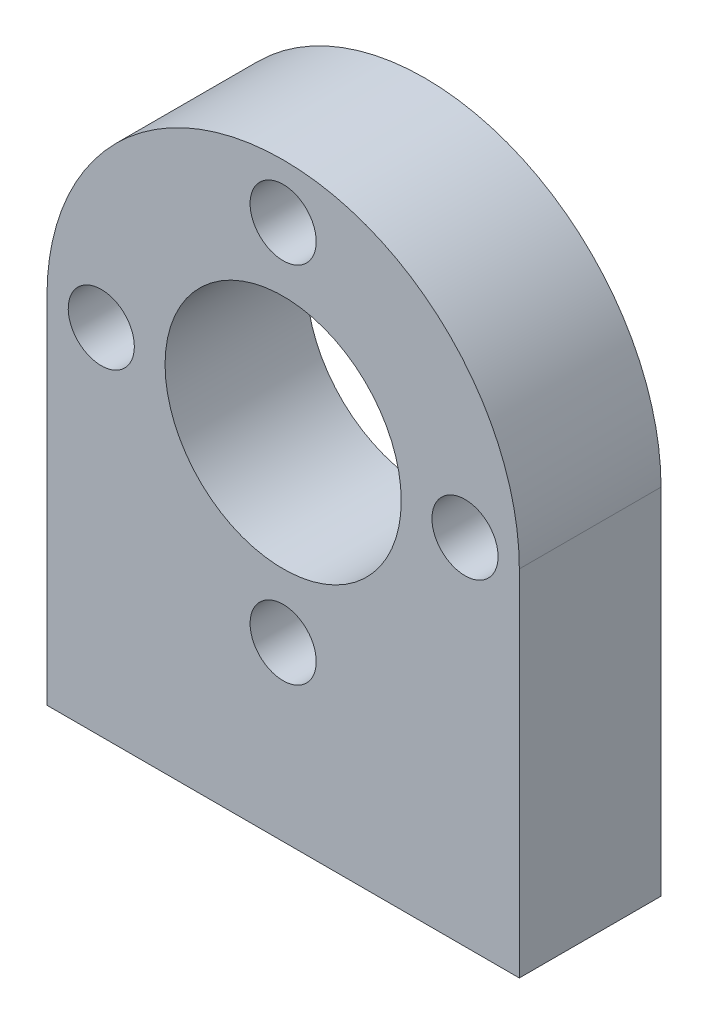
from build123d import *

# Parameters (mm, degrees)
SKETCH1_R           = 12.7
BOSS_EXTRUDE1_DEPTH = 7.62
SKETCH2_R           = 6.35
CUT_EXTRUDE1_DEPTH  = 7.62
SKETCH3_R           = 1.778
CUT_EXTRUDE2_DEPTH  = 7.62
CIRPATTERN1_COUNT   = 4


with BuildPart() as part:
    # Sketch1 → Boss-Extrude1 (new body)
    with BuildSketch(Plane.XY):
        with BuildLine():
            Line((0, -31.75), (0, -12.7))
            ThreePointArc((0, -12.7), (-12.699999961, -25.4), (-25.4, -12.700000079))
            Line((-25.4, -12.700000079), (-25.4, -31.75))
            Line((-25.4, -31.75), (0, -31.75))
        make_face()
        with Locations((-12.7, -12.7)):
            Circle(SKETCH1_R)
    extrude(amount=BOSS_EXTRUDE1_DEPTH)

    # Sketch2 → Cut-Extrude1 (cut)
    with BuildSketch(Plane.XY.offset(7.62)):
        with Locations((-12.7, -12.7)):
            Circle(SKETCH2_R)
    extrude(amount=-CUT_EXTRUDE1_DEPTH, mode=Mode.SUBTRACT)

    # Sketch3 → Cut-Extrude2 (cut)
    with BuildSketch(Plane.XY.offset(7.62)):
        with Locations((-12.7, -2.921)):
            Circle(SKETCH3_R)
    cut_extrude2 = extrude(amount=-CUT_EXTRUDE2_DEPTH, mode=Mode.SUBTRACT)

    # CirPattern1: Cut-Extrude2 ×4 about axis
    cirpattern1_axis = Axis((-12.7, -12.7, 0), (0, 0, 1))
    for i in range(1, CIRPATTERN1_COUNT):
        add(cut_extrude2.rotate(cirpattern1_axis, i * 360 / CIRPATTERN1_COUNT), mode=Mode.SUBTRACT)


solid = part.part
